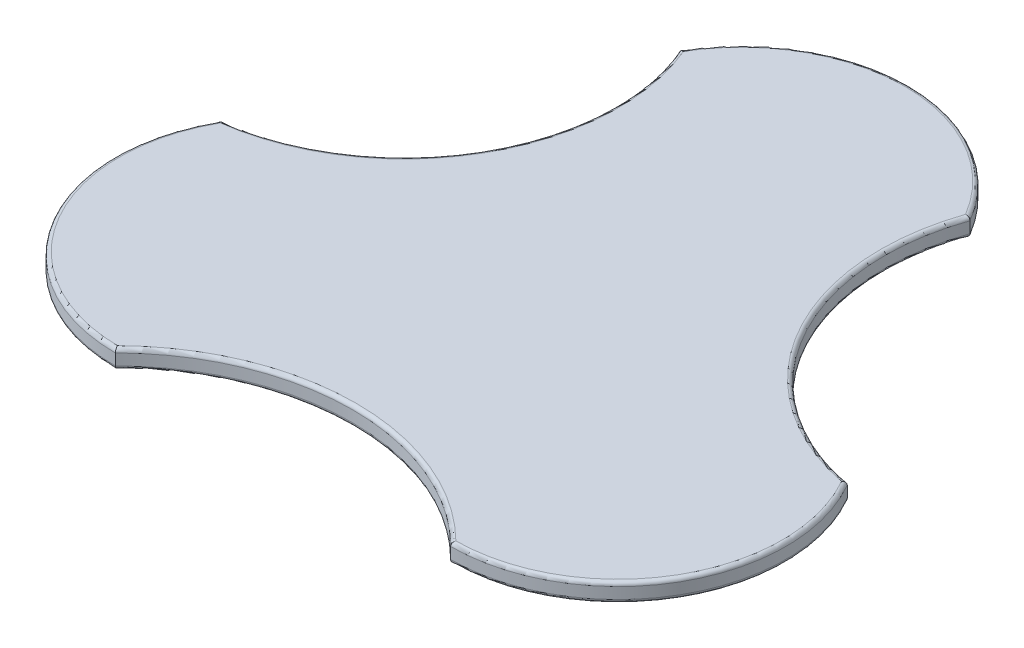
from build123d import *

# Parameters (mm, degrees)
BOSS_EXTRUDE1_DEPTH = 0.5
FILLET1_R           = 0.2


with BuildPart() as part:
    # Sketch1 → Boss-Extrude1 (new body, symmetric)
    with BuildSketch(Plane(origin=(0, 0, 0), x_dir=(1, 0, 0), z_dir=(0, 1, 0))):
        with BuildLine():
            ThreePointArc((-7.794228634, 4.5), (0.59695643, 10.04765189), (1.205771366, 20.088457268))
            ThreePointArc((1.205771366, 20.088457268), (9, 24.588457268), (16.794228634, 20.088457268))
            ThreePointArc((16.794228634, 20.088457268), (17.714119694, 10.227251774), (25.794228634, 4.5))
            ThreePointArc((25.794228634, 4.5), (25.794228634, -4.5), (18, -9))
            ThreePointArc((18, -9), (9, -5.272077939), (0, -9))
            ThreePointArc((0, -9), (-7.794228634, -4.5), (-7.794228634, 4.5))
        make_face()
    extrude(amount=BOSS_EXTRUDE1_DEPTH, both=True)

    # Fillet1
    fillet1_edges = [part.edges().sort_by_distance(p)[0] for p in [
        (0.59695643, 0.5, -10.04765189),
        (-7.794228634, 0.5, 4.5),
        (9, 0.5, 5.272077939),
        (25.794228634, 0.5, 4.5),
        (17.714119694, 0.5, -10.227251774),
        (25.794228634, -0.5, 4.5),
        (9, -0.5, 5.272077939),
        (-7.794228634, -0.5, 4.5),
        (9, 0.5, -24.588457268),
        (0.59695643, -0.5, -10.04765189),
        (9, -0.5, -24.588457268),
        (17.714119694, -0.5, -10.227251774),
    ]]
    fillet(fillet1_edges, radius=FILLET1_R)


solid = part.part
